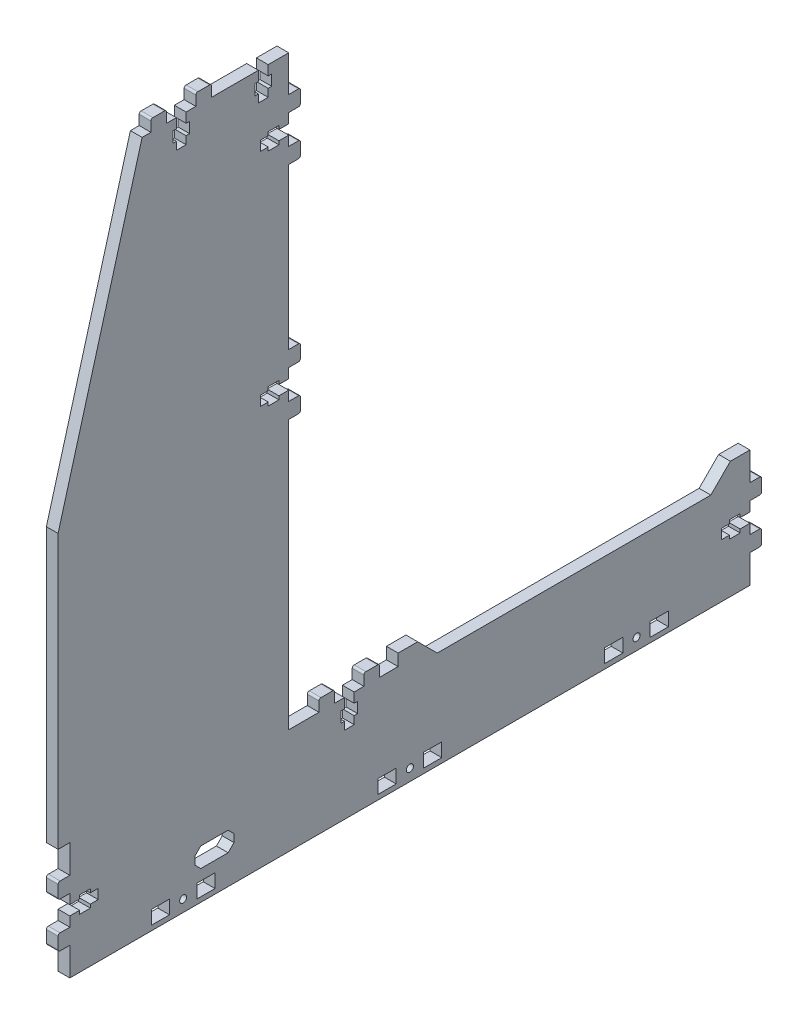
from build123d import *

# Parameters (mm, degrees)
ESQUISSE2_R             = 1.8
ESQUISSE2_W             = 9.3
ESQUISSE2_H             = 7
BOSS_EXTRU_1_DEPTH      = 3
BOSS_EXTRU_2_DEPTH      = 6
ENL_V_MAT_EXTRU_1_DEPTH = 6


with BuildPart() as part:
    # Esquisse2 → Boss.-Extru.1 (new, symmetric)
    with BuildSketch(Plane(origin=(0, 0, 0), x_dir=(0, 0, -1), z_dir=(1, 0, 0))):
        Polygon((-180, 200), (-180, 60), (-174, 60), (-174, 0), (174, 0), (174, 60), (164, 60), (154, 50), (14, 50), (4, 60), (-6, 60), (-6, 54), (-62, 54), (-62, 354), (-137, 354), align=None)
        with Locations((-116, 6)):
            Circle(ESQUISSE2_R, mode=Mode.SUBTRACT)
        with Locations((0, 6)):
            Circle(ESQUISSE2_R, mode=Mode.SUBTRACT)
        with Locations((116, 6)):
            Circle(ESQUISSE2_R, mode=Mode.SUBTRACT)
        with Locations((-127.65, 6)):
            Rectangle(ESQUISSE2_W, ESQUISSE2_H, mode=Mode.SUBTRACT)
        with Locations((-104.35, 6)):
            Rectangle(ESQUISSE2_W, ESQUISSE2_H, mode=Mode.SUBTRACT)
        with Locations((-11.65, 6)):
            Rectangle(ESQUISSE2_W, ESQUISSE2_H, mode=Mode.SUBTRACT)
        with Locations((11.65, 6)):
            Rectangle(ESQUISSE2_W, ESQUISSE2_H, mode=Mode.SUBTRACT)
        with Locations((127.65, 6)):
            Rectangle(ESQUISSE2_W, ESQUISSE2_H, mode=Mode.SUBTRACT)
        with Locations((104.35, 6)):
            Rectangle(ESQUISSE2_W, ESQUISSE2_H, mode=Mode.SUBTRACT)
    extrude(amount=BOSS_EXTRU_1_DEPTH, both=True)

    # Esquisse4 → Boss.-Extru.2 (add)
    with BuildSketch(Plane(origin=(3, 0, 0), x_dir=(0, 0, -1), z_dir=(1, 0, 0))):
        with BuildLine():
            Line((-179, 37.5), (-174, 37.5))
            Line((-174, 37.5), (-174, 45.5))
            Line((-174, 45.5), (-179, 45.5))
            ThreePointArc((-179, 45.5), (-179.707106781, 45.207106781), (-180, 44.5))
            Line((-180, 44.5), (-180, 38.5))
            ThreePointArc((-180, 38.5), (-179.707106781, 37.792893219), (-179, 37.5))
        make_face()
        with BuildLine():
            Line((-179, 14.5), (-174, 14.5))
            Line((-174, 14.5), (-174, 22.5))
            Line((-174, 22.5), (-179, 22.5))
            ThreePointArc((-179, 22.5), (-179.707106781, 22.207106781), (-180, 21.5))
            Line((-180, 21.5), (-180, 15.5))
            ThreePointArc((-180, 15.5), (-179.707106781, 14.792893219), (-179, 14.5))
        make_face()
        with BuildLine():
            Line((179, 22.5), (174, 22.5))
            Line((174, 22.5), (174, 14.5))
            Line((174, 14.5), (179, 14.5))
            ThreePointArc((179, 14.5), (179.707106781, 14.792893219), (180, 15.5))
            Line((180, 15.5), (180, 21.5))
            ThreePointArc((180, 21.5), (179.707106781, 22.207106781), (179, 22.5))
        make_face()
        with BuildLine():
            Line((179, 45.5), (174, 45.5))
            Line((174, 45.5), (174, 37.5))
            Line((174, 37.5), (179, 37.5))
            ThreePointArc((179, 37.5), (179.707106781, 37.792893219), (180, 38.5))
            Line((180, 38.5), (180, 44.5))
            ThreePointArc((180, 44.5), (179.707106781, 45.207106781), (179, 45.5))
        make_face()
        with BuildLine():
            Line((-23.5, 59), (-23.5, 54))
            Line((-23.5, 54), (-15.5, 54))
            Line((-15.5, 54), (-15.5, 59))
            ThreePointArc((-15.5, 59), (-15.792893219, 59.707106781), (-16.5, 60))
            Line((-16.5, 60), (-22.5, 60))
            ThreePointArc((-22.5, 60), (-23.207106781, 59.707106781), (-23.5, 59))
        make_face()
        with BuildLine():
            Line((-46.5, 59), (-46.5, 54))
            Line((-46.5, 54), (-38.5, 54))
            Line((-38.5, 54), (-38.5, 59))
            ThreePointArc((-38.5, 59), (-38.792893219, 59.707106781), (-39.5, 60))
            Line((-39.5, 60), (-45.5, 60))
            ThreePointArc((-45.5, 60), (-46.207106781, 59.707106781), (-46.5, 59))
        make_face()
        with BuildLine():
            Line((-57, 199.5), (-62, 199.5))
            Line((-62, 199.5), (-62, 191.5))
            Line((-62, 191.5), (-57, 191.5))
            ThreePointArc((-57, 191.5), (-56.292893219, 191.792893219), (-56, 192.5))
            Line((-56, 192.5), (-56, 198.5))
            ThreePointArc((-56, 198.5), (-56.292893219, 199.207106781), (-57, 199.5))
        make_face()
        with BuildLine():
            Line((-57, 222.5), (-62, 222.5))
            Line((-62, 222.5), (-62, 214.5))
            Line((-62, 214.5), (-57, 214.5))
            ThreePointArc((-57, 214.5), (-56.292893219, 214.792893219), (-56, 215.5))
            Line((-56, 215.5), (-56, 221.5))
            ThreePointArc((-56, 221.5), (-56.292893219, 222.207106781), (-57, 222.5))
        make_face()
        with BuildLine():
            Line((-57, 312.5), (-62, 312.5))
            Line((-62, 312.5), (-62, 304.5))
            Line((-62, 304.5), (-57, 304.5))
            ThreePointArc((-57, 304.5), (-56.292893219, 304.792893219), (-56, 305.5))
            Line((-56, 305.5), (-56, 311.5))
            ThreePointArc((-56, 311.5), (-56.292893219, 312.207106781), (-57, 312.5))
        make_face()
        with BuildLine():
            Line((-57, 335.5), (-62, 335.5))
            Line((-62, 335.5), (-62, 327.5))
            Line((-62, 327.5), (-57, 327.5))
            ThreePointArc((-57, 327.5), (-56.292893219, 327.792893219), (-56, 328.5))
            Line((-56, 328.5), (-56, 334.5))
            ThreePointArc((-56, 334.5), (-56.292893219, 335.207106781), (-57, 335.5))
        make_face()
        with BuildLine():
            Line((-109.5, 359), (-109.5, 354))
            Line((-109.5, 354), (-101.5, 354))
            Line((-101.5, 354), (-101.5, 359))
            ThreePointArc((-101.5, 359), (-101.792893219, 359.707106781), (-102.5, 360))
            Line((-102.5, 360), (-108.5, 360))
            ThreePointArc((-108.5, 360), (-109.207106781, 359.707106781), (-109.5, 359))
        make_face()
        with BuildLine():
            Line((-132.5, 359), (-132.5, 354))
            Line((-132.5, 354), (-124.5, 354))
            Line((-124.5, 354), (-124.5, 359))
            ThreePointArc((-124.5, 359), (-124.792893219, 359.707106781), (-125.5, 360))
            Line((-125.5, 360), (-131.5, 360))
            ThreePointArc((-131.5, 360), (-132.207106781, 359.707106781), (-132.5, 359))
        make_face()
    extrude(amount=-BOSS_EXTRU_2_DEPTH)

    # Esquisse4_3 → Enl_v. mat.-Extru.1 (cut)
    with BuildSketch(Plane(origin=(3, 0, 0), x_dir=(0, 0, -1), z_dir=(1, 0, 0))):
        Polygon((-174, 32.5), (-174, 27.5), (-169, 27.5), (-169, 25.7), (-163.5, 25.7), (-163.5, 27.5), (-159.5, 27.5), (-159.5, 32.5), (-163.5, 32.5), (-163.5, 34.3), (-169, 34.3), (-169, 32.5), align=None)
        Polygon((174, 27.5), (174, 32.5), (169, 32.5), (169, 34.3), (163.5, 34.3), (163.5, 32.5), (159.5, 32.5), (159.5, 27.5), (163.5, 27.5), (163.5, 25.7), (169, 25.7), (169, 27.5), align=None)
        Polygon((-28.5, 54), (-33.5, 54), (-33.5, 49), (-35.3, 49), (-35.3, 43.5), (-33.5, 43.5), (-33.5, 39.5), (-28.5, 39.5), (-28.5, 43.5), (-26.7, 43.5), (-26.7, 49), (-28.5, 49), align=None)
        Polygon((-62, 204.5), (-62, 209.5), (-67, 209.5), (-67, 211.3), (-72.5, 211.3), (-72.5, 209.5), (-76.5, 209.5), (-76.5, 204.5), (-72.5, 204.5), (-72.5, 202.7), (-67, 202.7), (-67, 204.5), align=None)
        Polygon((-62, 317.5), (-62, 322.5), (-67, 322.5), (-67, 324.3), (-72.5, 324.3), (-72.5, 322.5), (-76.5, 322.5), (-76.5, 317.5), (-72.5, 317.5), (-72.5, 315.7), (-67, 315.7), (-67, 317.5), align=None)
        Polygon((-72.5, 354), (-77.5, 354), (-77.5, 349), (-79.3, 349), (-79.3, 343.5), (-77.5, 343.5), (-77.5, 339.5), (-72.5, 339.5), (-72.5, 343.5), (-70.7, 343.5), (-70.7, 349), (-72.5, 349), align=None)
        Polygon((-114.5, 354), (-119.5, 354), (-119.5, 349), (-121.3, 349), (-121.3, 343.5), (-119.5, 343.5), (-119.5, 339.5), (-114.5, 339.5), (-114.5, 343.5), (-112.7, 343.5), (-112.7, 349), (-114.5, 349), align=None)
        Polygon((-107, 25), (-110, 22), (-110, 18), (-107, 15), (-93, 15), (-90, 18), (-90, 22), (-93, 25), align=None)
    extrude(amount=-ENL_V_MAT_EXTRU_1_DEPTH, mode=Mode.SUBTRACT)


solid = part.part
